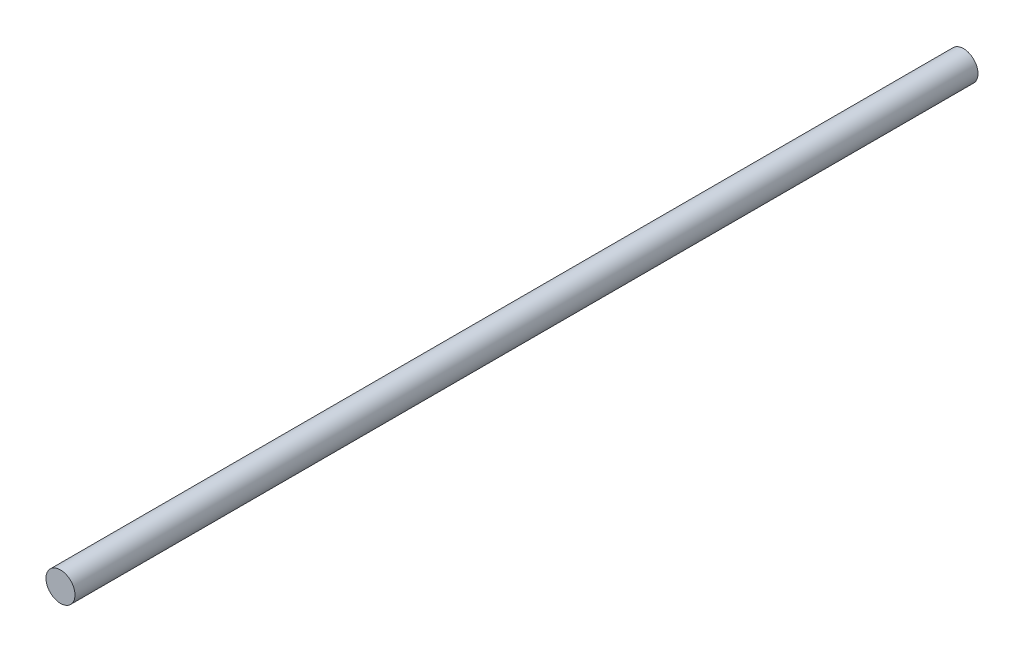
from build123d import *

# Parameters (mm, degrees)
SKETCH1_R           = 1.63195
BOSS_EXTRUDE1_DEPTH = 101.6


with BuildPart() as part:
    # Sketch1 → Boss-Extrude1 (new body)
    with BuildSketch(Plane.XY):
        Circle(SKETCH1_R)
    extrude(amount=BOSS_EXTRUDE1_DEPTH)


solid = part.part
